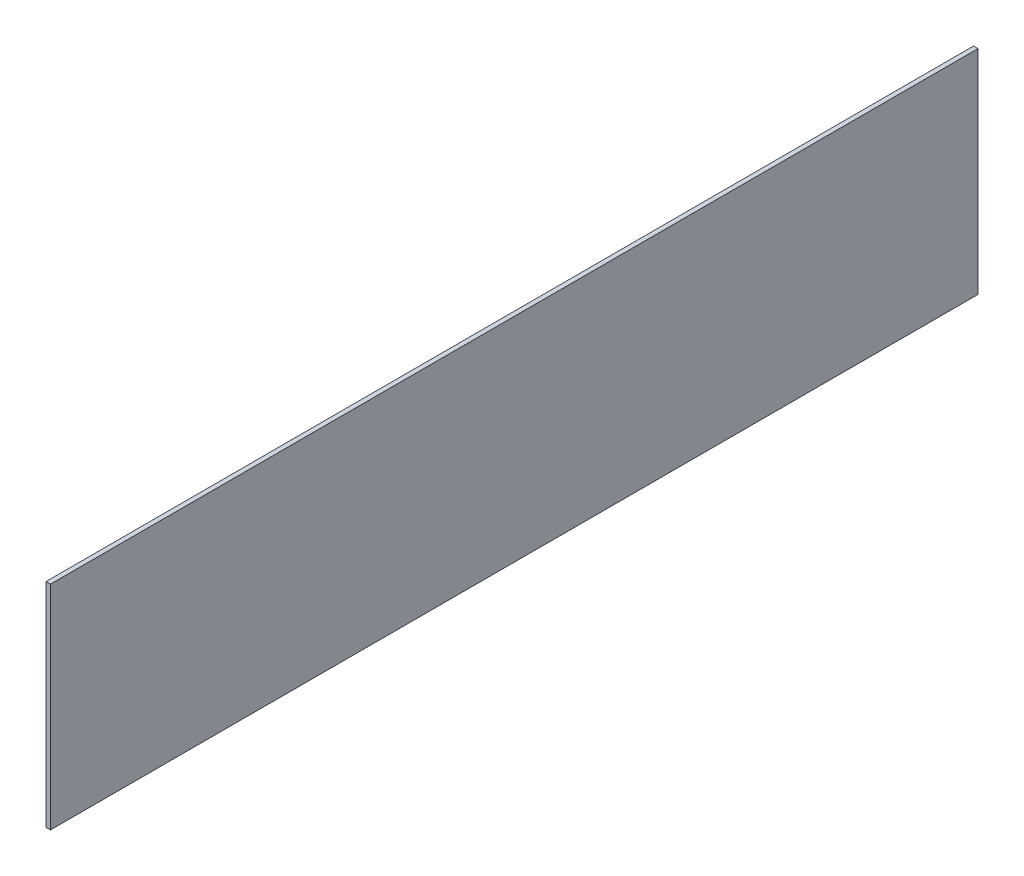
from build123d import *

# Parameters (mm, degrees)
BOSS_EXTRUDE1_DEPTH = 3


with BuildPart() as part:
    # Sketch1 → Boss-Extrude1 (new body)
    with BuildSketch(Plane(origin=(0, 0, 0), x_dir=(0, 0, -1), z_dir=(1, 0, 0))):
        Polygon((-311.5, 68.5), (-311.5, -71.5), (308.5, -71.5), (311.5, -71.5), (311.5, 68.5), (311.5, 71.5), (-311.5, 71.5), align=None)
    extrude(amount=BOSS_EXTRUDE1_DEPTH)


solid = part.part
